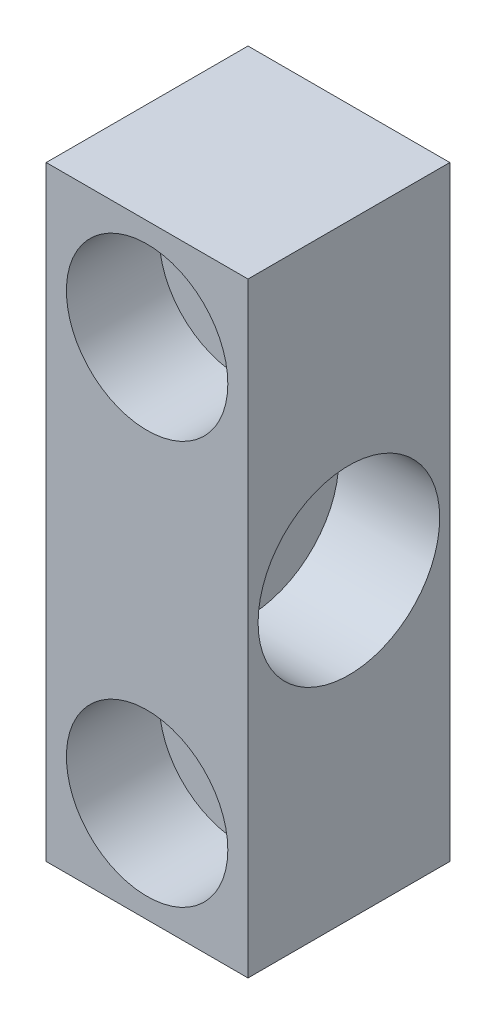
from build123d import *

# Parameters (mm, degrees)
SKETCH_1_W                = 10
SKETCH_1_H                = 30
EXTRUDE_1_DEPTH           = 10
HOLE_WIZARD_1_D           = 4.5
HOLE_WIZARD_1_CBORE_D     = 8
HOLE_WIZARD_1_CBORE_DEPTH = 4.6
HOLE_WIZARD_M5_1_D        = 4.2
SKETCH_6_R                = 4.5
CUT_EXTRUDE_1_DEPTH       = 5


with BuildPart() as part:
    # 草图1 → 凸台-拉伸1 (new body)
    with BuildSketch(Plane.XY):
        Rectangle(SKETCH_1_W, SKETCH_1_H)
    extrude(amount=EXTRUDE_1_DEPTH)

    # 打孔尺寸(%根据)内六角圆柱头螺钉的类型1 (through all)
    with Locations(Plane.XY.offset(10)):
        with Locations((0, 10), (0, -10)):
            CounterBoreHole(HOLE_WIZARD_1_D / 2, HOLE_WIZARD_1_CBORE_D / 2, HOLE_WIZARD_1_CBORE_DEPTH)

    # M5 螺纹孔1 (through all)
    with Locations(Plane(origin=(5, 0, 0), x_dir=(0, 0, -1), z_dir=(1, 0, 0))):
        with Locations((-5, 0)):
            Hole(HOLE_WIZARD_M5_1_D / 2)

    # 草图6 → 切除-拉伸1 (cut)
    with BuildSketch(Plane(origin=(5, 0, 0), x_dir=(0, 0, -1), z_dir=(1, 0, 0))):
        with Locations((-5, 0)):
            Circle(SKETCH_6_R)
    extrude(amount=-CUT_EXTRUDE_1_DEPTH, mode=Mode.SUBTRACT)


solid = part.part
